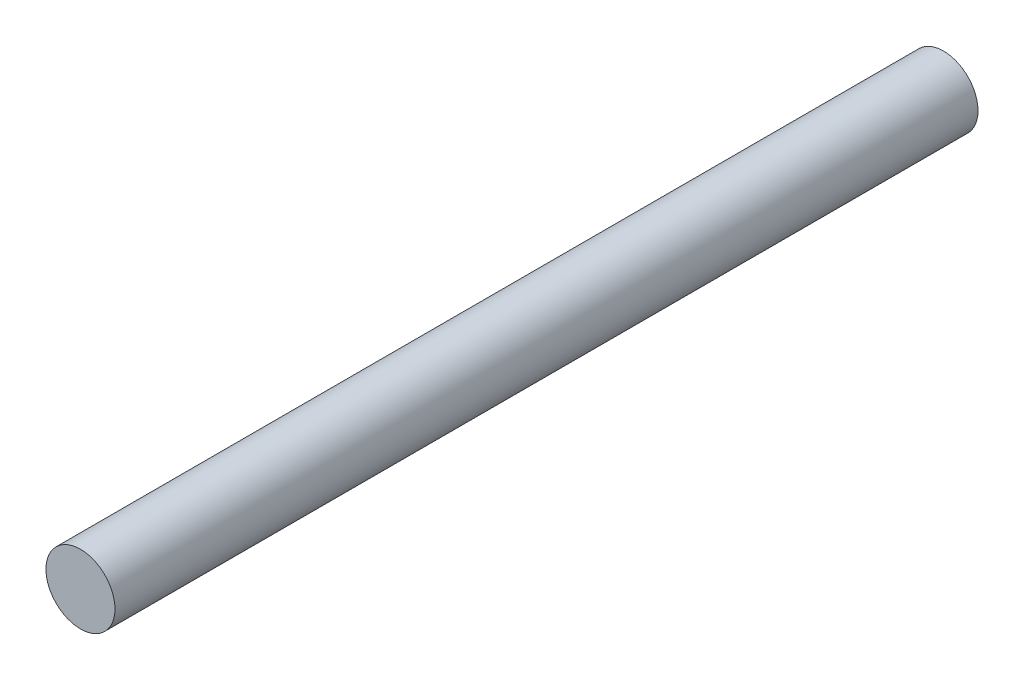
from build123d import *

# Parameters (mm, degrees)
ESQUISSE1_R        = 4
BOSS_EXTRU_1_DEPTH = 100


with BuildPart() as part:
    # Esquisse1 → Boss.-Extru.1 (new body)
    with BuildSketch(Plane.XY):
        with Locations((33.96987509, 0)):
            Circle(ESQUISSE1_R)
    extrude(amount=BOSS_EXTRU_1_DEPTH)


solid = part.part
